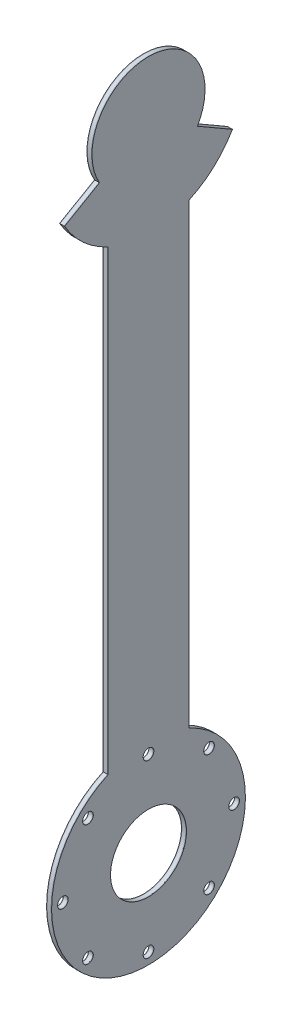
from build123d import *

# Parameters (mm, degrees)
BOSS_EXTRUDE1_DEPTH           = 0.1
BOSS_EXTRUDE1_DEPTH_BACK      = 0.25
SKETCH1_R                     = 23.5
SKETCH2_R                     = 23.5
BOSS_EXTRUDE2_DEPTH           = 2.5
SKETCH4_R                     = 23.5
BOSS_EXTRUDE3_DEPTH           = 0.25
SKETCH6_W                     = 3.3
SKETCH6_H                     = 3.1
M6_CLEARANCE_HOLE1_AT_2_COUNT = 2
M6_CLEARANCE_HOLE1_AT_2_PITCH = 40.564443831
M6_CLEARANCE_HOLE1_AT_3_COUNT = 2
M6_CLEARANCE_HOLE1_AT_3_PITCH = 74.953318806
M6_CLEARANCE_HOLE1_AT_4_COUNT = 2
M6_CLEARANCE_HOLE1_AT_4_PITCH = 97.931230446
M6_CLEARANCE_HOLE1_AT_5_COUNT = 2
M6_CLEARANCE_HOLE1_AT_5_PITCH = 106
M6_CLEARANCE_HOLE1_AT_6_COUNT = 2
M6_CLEARANCE_HOLE1_AT_6_PITCH = 97.931230446
M6_CLEARANCE_HOLE1_AT_7_COUNT = 2
M6_CLEARANCE_HOLE1_AT_7_PITCH = 74.953318806
M6_CLEARANCE_HOLE1_AT_8_COUNT = 2
M6_CLEARANCE_HOLE1_AT_8_PITCH = 40.564443831


with BuildPart() as part:
    # Sketch1 → Boss-Extrude1 (new, two sides: drawn at the far end of the back side and taken through both)
    with BuildSketch(Plane(origin=(0, 0, 0), x_dir=(0, 0, -1), z_dir=(1, 0, 0)).offset(-BOSS_EXTRUDE1_DEPTH_BACK)):
        with BuildLine():
            Line((51.961524227, -30), (30.310889132, -17.5))
            ThreePointArc((30.310889132, -17.5), (0, 35), (-30.310889132, -17.5))
            Line((-30.310889132, -17.5), (-51.961524227, -30))
            ThreePointArc((-51.961524227, -30), (-40.390167668, -44.369295191), (-25, -54.543560573))
            Line((-25, -54.543560573), (-25, -337.456439427))
            ThreePointArc((-25, -337.456439427), (0, -452), (25, -337.456439427))
            Line((25, -337.456439427), (25, -54.543560573))
            ThreePointArc((25, -54.543560573), (40.390167668, -44.369295191), (51.961524227, -30))
        make_face()
        with Locations((0, -392)):
            Circle(SKETCH1_R, mode=Mode.SUBTRACT)
    extrude(amount=BOSS_EXTRUDE1_DEPTH + BOSS_EXTRUDE1_DEPTH_BACK)


with BuildPart() as body_2:
    # Sketch2 → Boss-Extrude2 (new body)
    with BuildSketch(Plane.ZY.offset(0.25)):
        with BuildLine():
            ThreePointArc((30.310889132, -17.5), (0, 35), (-30.310889132, -17.5))
            Line((-30.310889132, -17.5), (-51.961524227, -30))
            ThreePointArc((-51.961524227, -30), (-40.390167668, -44.369295191), (-25, -54.543560573))
            Line((-25, -54.543560573), (-25, -337.456439427))
            ThreePointArc((-25, -337.456439427), (0, -452), (25, -337.456439427))
            Line((25, -337.456439427), (25, -54.543560573))
            ThreePointArc((25, -54.543560573), (40.390167668, -44.369295191), (51.961524227, -30))
            Line((51.961524227, -30), (30.310889132, -17.5))
        make_face()
        with Locations((0, -392)):
            Circle(SKETCH2_R, mode=Mode.SUBTRACT)
    extrude(amount=BOSS_EXTRUDE2_DEPTH)


with BuildPart() as body_3:
    # Sketch4 → Boss-Extrude3 (new body)
    with BuildSketch(Plane.ZY.offset(2.75)):
        with BuildLine():
            Line((51.961524227, -30), (30.310889132, -17.5))
            ThreePointArc((30.310889132, -17.5), (0, 35), (-30.310889132, -17.5))
            Line((-30.310889132, -17.5), (-51.961524227, -30))
            ThreePointArc((-51.961524227, -30), (-40.390167668, -44.369295191), (-25, -54.543560573))
            Line((-25, -54.543560573), (-25, -337.456439427))
            ThreePointArc((-25, -337.456439427), (0, -452), (25, -337.456439427))
            Line((25, -337.456439427), (25, -54.543560573))
            ThreePointArc((25, -54.543560573), (40.390167668, -44.369295191), (51.961524227, -30))
        make_face()
        with Locations((0, -392)):
            Circle(SKETCH4_R, mode=Mode.SUBTRACT)
    extrude(amount=BOSS_EXTRUDE3_DEPTH)


with BuildPart() as m6_clearance_hole1_tool:
    # Sketch6 → M6 Clearance Hole1 (revolve)
    with BuildSketch(Plane(origin=(0.1, -354.523340597, -37.476659403), x_dir=(0, 0, -1), z_dir=(0, 1, 0))):
        with Locations((1.65, 1.55)):
            Rectangle(SKETCH6_W, SKETCH6_H)
    m6_clearance_hole1 = revolve(axis=Axis((6.45, -354.523340597, -37.476659403), (-1, 0, 0)))


with BuildPart() as part_1:
    add(part.part)

    # M6 Clearance Hole1: cut by m6_clearance_hole1_tool
    add(m6_clearance_hole1_tool.part, mode=Mode.SUBTRACT)


with BuildPart() as body_2_1:
    add(body_2.part)

    # M6 Clearance Hole1: cut by m6_clearance_hole1_tool
    add(m6_clearance_hole1_tool.part, mode=Mode.SUBTRACT)


with BuildPart() as body_3_1:
    add(body_3.part)

    # M6 Clearance Hole1: cut by m6_clearance_hole1_tool
    add(m6_clearance_hole1_tool.part, mode=Mode.SUBTRACT)


with BuildPart() as m6_clearance_hole1_at_2_tool:
    # M6 Clearance Hole1 at 2: M6 Clearance Hole1 ×2
    with Locations(*[Vector(0, -0.9238795325112888, -0.38268343236508495) * (i * M6_CLEARANCE_HOLE1_AT_2_PITCH) for i in range(1, M6_CLEARANCE_HOLE1_AT_2_COUNT)]):
        add(m6_clearance_hole1)


with BuildPart() as part_2:
    add(part_1.part)

    # M6 Clearance Hole1 at 2: cut by m6_clearance_hole1_at_2_tool
    add(m6_clearance_hole1_at_2_tool.part, mode=Mode.SUBTRACT)


with BuildPart() as body_2_2:
    add(body_2_1.part)

    # M6 Clearance Hole1 at 2: cut by m6_clearance_hole1_at_2_tool
    add(m6_clearance_hole1_at_2_tool.part, mode=Mode.SUBTRACT)


with BuildPart() as body_3_2:
    add(body_3_1.part)

    # M6 Clearance Hole1 at 2: cut by m6_clearance_hole1_at_2_tool
    add(m6_clearance_hole1_at_2_tool.part, mode=Mode.SUBTRACT)


with BuildPart() as m6_clearance_hole1_at_3_tool:
    # M6 Clearance Hole1 at 3: M6 Clearance Hole1 ×2
    with Locations(*[(0, -i * M6_CLEARANCE_HOLE1_AT_3_PITCH, 0) for i in range(1, M6_CLEARANCE_HOLE1_AT_3_COUNT)]):
        add(m6_clearance_hole1)


with BuildPart() as part_3:
    add(part_2.part)

    # M6 Clearance Hole1 at 3: cut by m6_clearance_hole1_at_3_tool
    add(m6_clearance_hole1_at_3_tool.part, mode=Mode.SUBTRACT)


with BuildPart() as body_2_3:
    add(body_2_2.part)

    # M6 Clearance Hole1 at 3: cut by m6_clearance_hole1_at_3_tool
    add(m6_clearance_hole1_at_3_tool.part, mode=Mode.SUBTRACT)


with BuildPart() as body_3_3:
    add(body_3_2.part)

    # M6 Clearance Hole1 at 3: cut by m6_clearance_hole1_at_3_tool
    add(m6_clearance_hole1_at_3_tool.part, mode=Mode.SUBTRACT)


with BuildPart() as m6_clearance_hole1_at_4_tool:
    # M6 Clearance Hole1 at 4: M6 Clearance Hole1 ×2
    with Locations(*[Vector(0, -0.9238795325112837, 0.38268343236509716) * (i * M6_CLEARANCE_HOLE1_AT_4_PITCH) for i in range(1, M6_CLEARANCE_HOLE1_AT_4_COUNT)]):
        add(m6_clearance_hole1)


with BuildPart() as part_4:
    add(part_3.part)

    # M6 Clearance Hole1 at 4: cut by m6_clearance_hole1_at_4_tool
    add(m6_clearance_hole1_at_4_tool.part, mode=Mode.SUBTRACT)


with BuildPart() as body_2_4:
    add(body_2_3.part)

    # M6 Clearance Hole1 at 4: cut by m6_clearance_hole1_at_4_tool
    add(m6_clearance_hole1_at_4_tool.part, mode=Mode.SUBTRACT)


with BuildPart() as body_3_4:
    add(body_3_3.part)

    # M6 Clearance Hole1 at 4: cut by m6_clearance_hole1_at_4_tool
    add(m6_clearance_hole1_at_4_tool.part, mode=Mode.SUBTRACT)


with BuildPart() as m6_clearance_hole1_at_5_tool:
    # M6 Clearance Hole1 at 5: M6 Clearance Hole1 ×2
    with Locations(*[Vector(0, -0.7071067811865405, 0.7071067811865547) * (i * M6_CLEARANCE_HOLE1_AT_5_PITCH) for i in range(1, M6_CLEARANCE_HOLE1_AT_5_COUNT)]):
        add(m6_clearance_hole1)


with BuildPart() as part_5:
    add(part_4.part)

    # M6 Clearance Hole1 at 5: cut by m6_clearance_hole1_at_5_tool
    add(m6_clearance_hole1_at_5_tool.part, mode=Mode.SUBTRACT)


with BuildPart() as body_2_5:
    add(body_2_4.part)

    # M6 Clearance Hole1 at 5: cut by m6_clearance_hole1_at_5_tool
    add(m6_clearance_hole1_at_5_tool.part, mode=Mode.SUBTRACT)


with BuildPart() as body_3_5:
    add(body_3_4.part)

    # M6 Clearance Hole1 at 5: cut by m6_clearance_hole1_at_5_tool
    add(m6_clearance_hole1_at_5_tool.part, mode=Mode.SUBTRACT)


with BuildPart() as m6_clearance_hole1_at_6_tool:
    # M6 Clearance Hole1 at 6: M6 Clearance Hole1 ×2
    with Locations(*[Vector(0, -0.3826834323650799, 0.9238795325112908) * (i * M6_CLEARANCE_HOLE1_AT_6_PITCH) for i in range(1, M6_CLEARANCE_HOLE1_AT_6_COUNT)]):
        add(m6_clearance_hole1)


with BuildPart() as part_6:
    add(part_5.part)

    # M6 Clearance Hole1 at 6: cut by m6_clearance_hole1_at_6_tool
    add(m6_clearance_hole1_at_6_tool.part, mode=Mode.SUBTRACT)


with BuildPart() as body_2_6:
    add(body_2_5.part)

    # M6 Clearance Hole1 at 6: cut by m6_clearance_hole1_at_6_tool
    add(m6_clearance_hole1_at_6_tool.part, mode=Mode.SUBTRACT)


with BuildPart() as body_3_6:
    add(body_3_5.part)

    # M6 Clearance Hole1 at 6: cut by m6_clearance_hole1_at_6_tool
    add(m6_clearance_hole1_at_6_tool.part, mode=Mode.SUBTRACT)


with BuildPart() as m6_clearance_hole1_at_7_tool:
    # M6 Clearance Hole1 at 7: M6 Clearance Hole1 ×2
    with Locations(*[(0, 0, i * M6_CLEARANCE_HOLE1_AT_7_PITCH) for i in range(1, M6_CLEARANCE_HOLE1_AT_7_COUNT)]):
        add(m6_clearance_hole1)


with BuildPart() as part_7:
    add(part_6.part)

    # M6 Clearance Hole1 at 7: cut by m6_clearance_hole1_at_7_tool
    add(m6_clearance_hole1_at_7_tool.part, mode=Mode.SUBTRACT)


with BuildPart() as body_2_7:
    add(body_2_6.part)

    # M6 Clearance Hole1 at 7: cut by m6_clearance_hole1_at_7_tool
    add(m6_clearance_hole1_at_7_tool.part, mode=Mode.SUBTRACT)


with BuildPart() as body_3_7:
    add(body_3_6.part)

    # M6 Clearance Hole1 at 7: cut by m6_clearance_hole1_at_7_tool
    add(m6_clearance_hole1_at_7_tool.part, mode=Mode.SUBTRACT)


with BuildPart() as m6_clearance_hole1_at_8_tool:
    # M6 Clearance Hole1 at 8: M6 Clearance Hole1 ×2
    with Locations(*[Vector(0, 0.38268343236510227, 0.9238795325112816) * (i * M6_CLEARANCE_HOLE1_AT_8_PITCH) for i in range(1, M6_CLEARANCE_HOLE1_AT_8_COUNT)]):
        add(m6_clearance_hole1)


with BuildPart() as part_8:
    add(part_7.part)

    # M6 Clearance Hole1 at 8: cut by m6_clearance_hole1_at_8_tool
    add(m6_clearance_hole1_at_8_tool.part, mode=Mode.SUBTRACT)


with BuildPart() as body_2_8:
    add(body_2_7.part)

    # M6 Clearance Hole1 at 8: cut by m6_clearance_hole1_at_8_tool
    add(m6_clearance_hole1_at_8_tool.part, mode=Mode.SUBTRACT)


with BuildPart() as body_3_8:
    add(body_3_7.part)

    # M6 Clearance Hole1 at 8: cut by m6_clearance_hole1_at_8_tool
    add(m6_clearance_hole1_at_8_tool.part, mode=Mode.SUBTRACT)


solid = Compound([part_8.part, body_2_8.part, body_3_8.part])
